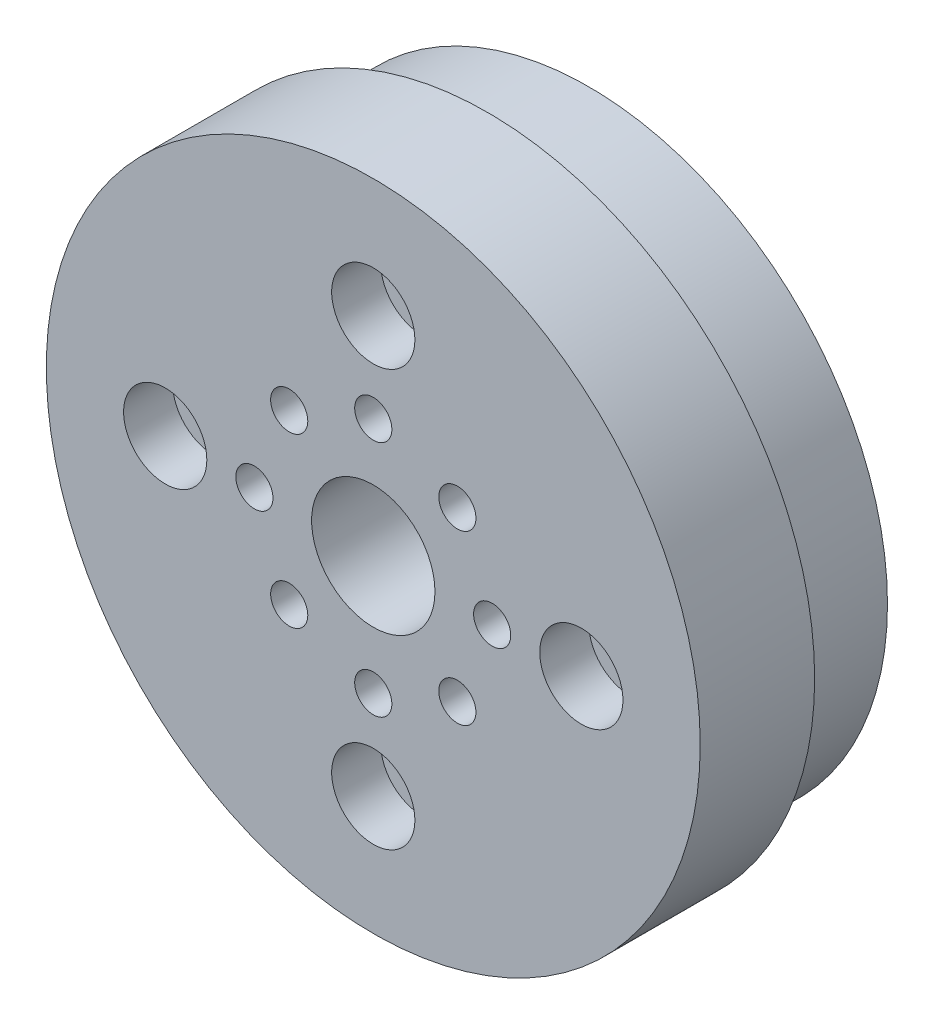
from build123d import *

# Parameters (mm, degrees)
SKETCH1_R           = 22
BOSS_EXTRUDE1_DEPTH = 7.7
SKETCH2_R           = 20.1
SKETCH2_R_2         = 18.1
BOSS_EXTRUDE2_DEPTH = 6.8
SKETCH3_R           = 4.15
SKETCH3_R_2         = 1.25
CUT_EXTRUDE1_DEPTH  = 15.5
SKETCH4_R           = 2.8
CUT_EXTRUDE2_DEPTH  = 3.3
SKETCH6_R           = 1.6
CUT_EXTRUDE3_DEPTH  = 15.5


with BuildPart() as part:
    # Sketch1 → Boss-Extrude1 (new body)
    with BuildSketch(Plane.XY):
        Circle(SKETCH1_R)
    extrude(amount=BOSS_EXTRUDE1_DEPTH)

    # Sketch2 → Boss-Extrude2 (add)
    with BuildSketch(Plane(origin=(0, 0, 0), x_dir=(-1, 0, 0), z_dir=(0, 0, -1))):
        Circle(SKETCH2_R)
        Circle(SKETCH2_R_2, mode=Mode.SUBTRACT)
    extrude(amount=BOSS_EXTRUDE2_DEPTH)

    # Sketch3 → Cut-Extrude1 (cut, through all)
    with BuildSketch(Plane.XY.offset(7.7)):
        Circle(SKETCH3_R)
        with Locations((0, 8)):
            Circle(SKETCH3_R_2)
        with Locations((5.656854249, 5.656854249)):
            Circle(SKETCH3_R_2)
        with Locations((8, 0)):
            Circle(SKETCH3_R_2)
        with Locations((5.656854249, -5.656854249)):
            Circle(SKETCH3_R_2)
        with Locations((0, -8)):
            Circle(SKETCH3_R_2)
        with Locations((-5.656854249, -5.656854249)):
            Circle(SKETCH3_R_2)
        with Locations((-8, 0)):
            Circle(SKETCH3_R_2)
        with Locations((-5.656854249, 5.656854249)):
            Circle(SKETCH3_R_2)
    extrude(amount=-CUT_EXTRUDE1_DEPTH, mode=Mode.SUBTRACT)

    # Sketch4 → Cut-Extrude2 (cut)
    with BuildSketch(Plane.XY.offset(7.7)):
        with Locations((14, 0)):
            Circle(SKETCH4_R)
        with Locations((0, -14)):
            Circle(SKETCH4_R)
        with Locations((-14, 0)):
            Circle(SKETCH4_R)
        with Locations((0, 14)):
            Circle(SKETCH4_R)
    extrude(amount=-CUT_EXTRUDE2_DEPTH, mode=Mode.SUBTRACT)

    # Sketch6 → Cut-Extrude3 (cut, through all)
    with BuildSketch(Plane.XY.offset(7.7)):
        with Locations((14, 0)):
            Circle(SKETCH6_R)
        with Locations((0, -14)):
            Circle(SKETCH6_R)
        with Locations((-14, 0)):
            Circle(SKETCH6_R)
        with Locations((0, 14)):
            Circle(SKETCH6_R)
    extrude(amount=-CUT_EXTRUDE3_DEPTH, mode=Mode.SUBTRACT)


solid = part.part
